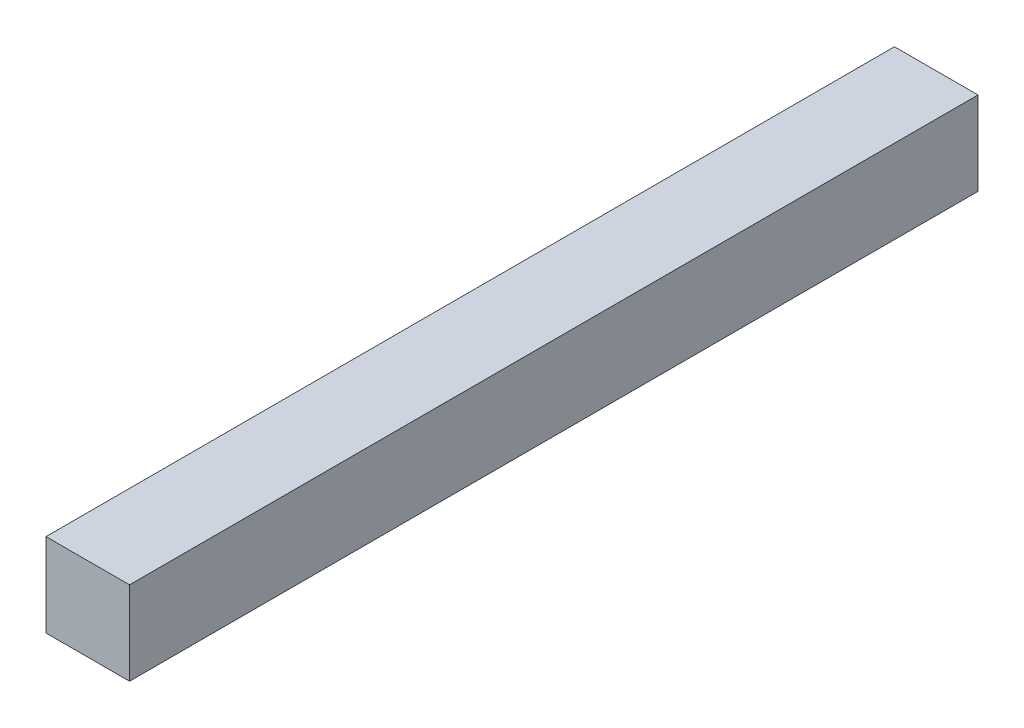
from build123d import *

# Parameters (mm, degrees)
SKETCH1_W           = 10
SKETCH1_H           = 10
BOSS_EXTRUDE1_DEPTH = 101.6025


with BuildPart() as part:
    # Sketch1 → Boss-Extrude1 (new body)
    with BuildSketch(Plane.XY):
        Rectangle(SKETCH1_W, SKETCH1_H)
    extrude(amount=BOSS_EXTRUDE1_DEPTH)


solid = part.part
